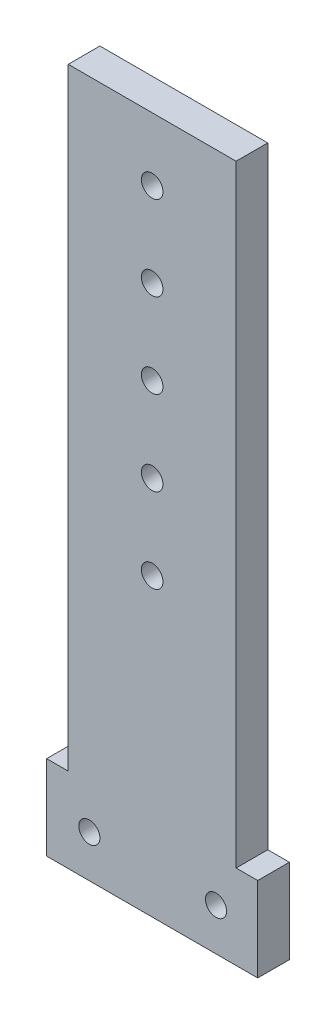
from build123d import *

# Parameters (mm, degrees)
SKETCH1_R           = 3.175
SKETCH1_R_2         = 3.25
BOSS_EXTRUDE1_DEPTH = 9.525


with BuildPart() as part:
    # Sketch1 → Boss-Extrude1 (new body)
    with BuildSketch(Plane.XY):
        Polygon((0.15, 19.05), (0.15, 203.2), (50.65, 203.2), (50.65, 19.05), (57.15, 19.05), (57.15, -6.35), (-6.35, -6.35), (-6.35, 19.05), align=None)
        with Locations((6.5, 6.35)):
            Circle(SKETCH1_R, mode=Mode.SUBTRACT)
        with Locations((44.6, 6.35)):
            Circle(SKETCH1_R, mode=Mode.SUBTRACT)
        with Locations((25.4, 184.2)):
            Circle(SKETCH1_R_2, mode=Mode.SUBTRACT)
        with Locations((25.4, 158.8)):
            Circle(SKETCH1_R_2, mode=Mode.SUBTRACT)
        with Locations((25.4, 133.4)):
            Circle(SKETCH1_R_2, mode=Mode.SUBTRACT)
        with Locations((25.4, 108)):
            Circle(SKETCH1_R_2, mode=Mode.SUBTRACT)
        with Locations((25.4, 82.6)):
            Circle(SKETCH1_R_2, mode=Mode.SUBTRACT)
    extrude(amount=BOSS_EXTRUDE1_DEPTH)


solid = part.part
